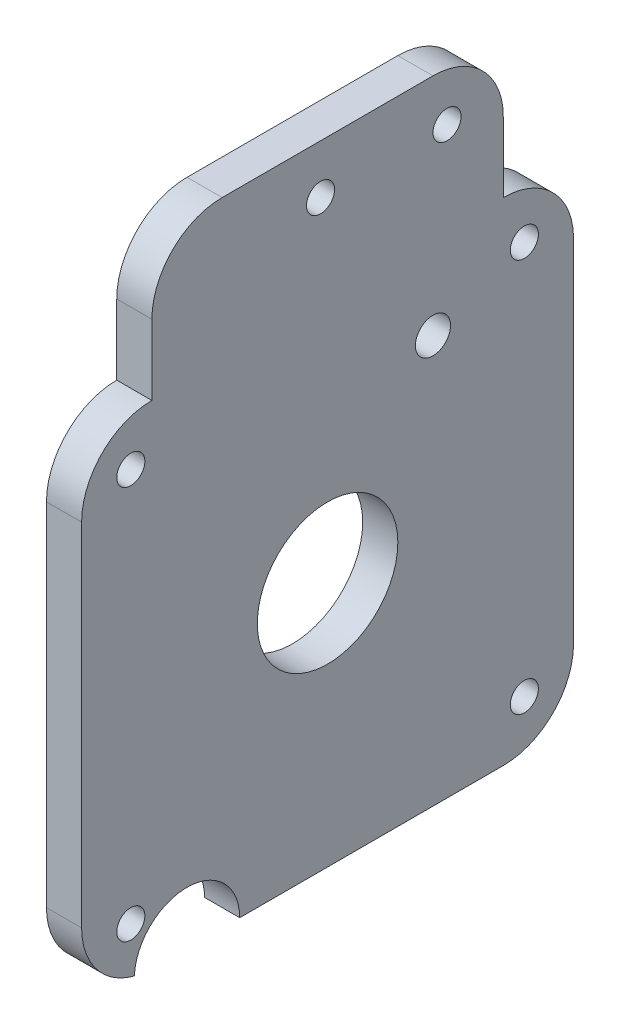
from build123d import *

# Parameters (mm, degrees)
CROQUIS1_R              = 2
CROQUIS1_R_2            = 10
SALIENTE_EXTRUIR1_DEPTH = 5
CROQUIS2_R              = 7.5
CROQUIS2_R_2            = 2.5
CROQUIS2_R_3            = 2
CORTAR_EXTRUIR1_DEPTH   = 10


with BuildPart() as part:
    # Croquis1 → Saliente-Extruir1 (new body)
    with BuildSketch(Plane(origin=(0, 0, 0), x_dir=(0, 0, -1), z_dir=(1, 0, 0))):
        with BuildLine():
            Line((10, 0), (60, 0))
            ThreePointArc((60, 0), (67.071067812, 2.928932188), (70, 10))
            Line((70, 10), (70, 60))
            ThreePointArc((70, 60), (67.071067812, 67.071067812), (60, 70))
            Line((60, 70), (60, 80))
            ThreePointArc((60, 80), (57.071067812, 87.071067812), (50, 90))
            Line((50, 90), (20, 90))
            ThreePointArc((20, 90), (12.928932188, 87.071067812), (10, 80))
            Line((10, 80), (10, 70))
            ThreePointArc((10, 70), (2.928932188, 67.071067812), (0, 60))
            Line((0, 60), (0, 10))
            ThreePointArc((0, 10), (2.928932188, 2.928932188), (10, 0))
        make_face()
        with Locations((7, 63)):
            Circle(CROQUIS1_R, mode=Mode.SUBTRACT)
        with Locations((63, 63)):
            Circle(CROQUIS1_R, mode=Mode.SUBTRACT)
        with Locations((63, 7)):
            Circle(CROQUIS1_R, mode=Mode.SUBTRACT)
        with Locations((7, 7)):
            Circle(CROQUIS1_R, mode=Mode.SUBTRACT)
        with Locations((35, 35)):
            Circle(CROQUIS1_R_2, mode=Mode.SUBTRACT)
    extrude(amount=SALIENTE_EXTRUIR1_DEPTH)

    # Croquis2 → Cortar-Extruir1 (cut)
    with BuildSketch(Plane(origin=(5, 0, 0), x_dir=(0, 0, -1), z_dir=(1, 0, 0))):
        with Locations((15, 0)):
            Circle(CROQUIS2_R)
        with Locations((50, 58)):
            Circle(CROQUIS2_R_2)
        with Locations((52, 83)):
            Circle(CROQUIS2_R_3)
        with Locations((34, 83)):
            Circle(CROQUIS2_R_3)
    extrude(amount=-CORTAR_EXTRUIR1_DEPTH, mode=Mode.SUBTRACT)


solid = part.part
